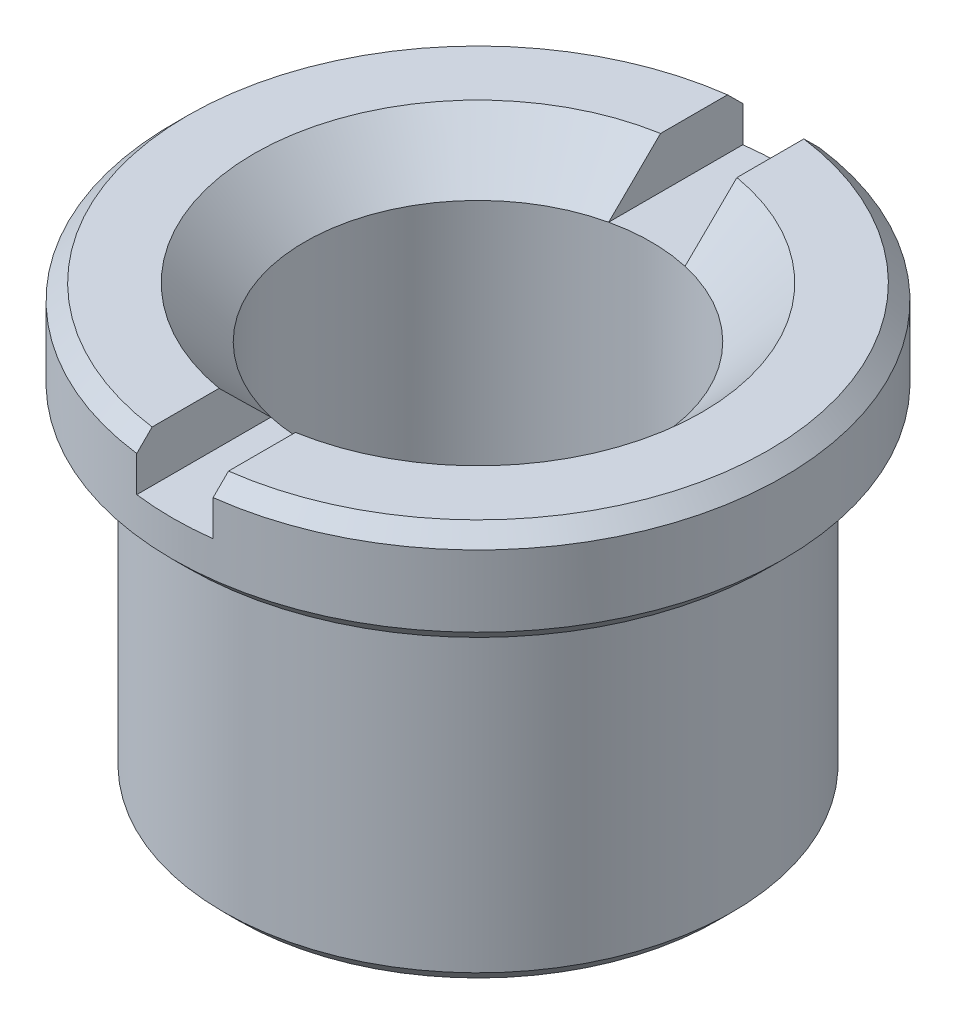
from build123d import *

# Parameters (mm, degrees)
ESQUISSE1_R             = 5
EXTRUSION1_DEPTH        = 6.5
ESQUISSE2_R             = 6
EXTRUSION2_DEPTH        = 2
ESQUISSE3_R             = 3.4
ENL_V_MAT_EXTRU_1_DEPTH = 9.5
CHANFREIN1_SIZE         = 0.3
CHANFREIN2_SIZE         = 1
ESQUISSE4_W             = 1.5
ESQUISSE4_H             = 12
ENL_V_MAT_EXTRU_2_DEPTH = 1


with BuildPart() as part:
    # Esquisse1 → Extrusion1 (new body)
    with BuildSketch(Plane(origin=(0, 0, 0), x_dir=(1, 0, 0), z_dir=(0, 1, 0))):
        with Locations(Location((0, 0, 0), (0, 0, 270))):  # turned: the seam where the file's is
            Circle(ESQUISSE1_R)
    extrude(amount=-EXTRUSION1_DEPTH)

    # Esquisse2 → Extrusion2 (add)
    with BuildSketch(Plane(origin=(0, 0, 0), x_dir=(-1, 0, 0), z_dir=(0, 1, 0))):
        with Locations(Location((0, 0, 0), (0, 0, 90))):  # turned: the seam where the file's is
            Circle(ESQUISSE2_R)
    extrude(amount=EXTRUSION2_DEPTH)

    # Esquisse3 → Enlèv. mat.-Extru.1 (cut, through all)
    with BuildSketch(Plane(origin=(0, 2, 0), x_dir=(-1, 0, 0), z_dir=(0, 1, 0))):
        with Locations(Location((0, 0, 0), (0, 0, 90))):  # turned: the seam where the file's is
            Circle(ESQUISSE3_R)
    extrude(amount=-ENL_V_MAT_EXTRU_1_DEPTH, mode=Mode.SUBTRACT)

    # Chanfrein1
    chanfrein1_edges = [part.edges().sort_by_distance(p)[0] for p in [
        (0, -6.5, -5),
        (0, 0, -6),
        (0, 2, -6),
    ]]
    chamfer(chanfrein1_edges, length=CHANFREIN1_SIZE)

    # Chanfrein2
    chanfrein2_edges = [part.edges().sort_by_distance(p)[0] for p in [
        (0, 2, -3.4),
    ]]
    chamfer(chanfrein2_edges, length=CHANFREIN2_SIZE)

    # Esquisse4 → Enlèv. mat.-Extru.2 (cut)
    with BuildSketch(Plane(origin=(0, 2, 0), x_dir=(-1, 0, 0), z_dir=(0, 1, 0))):
        Rectangle(ESQUISSE4_W, ESQUISSE4_H)
    extrude(amount=-ENL_V_MAT_EXTRU_2_DEPTH, mode=Mode.SUBTRACT)


solid = part.part
